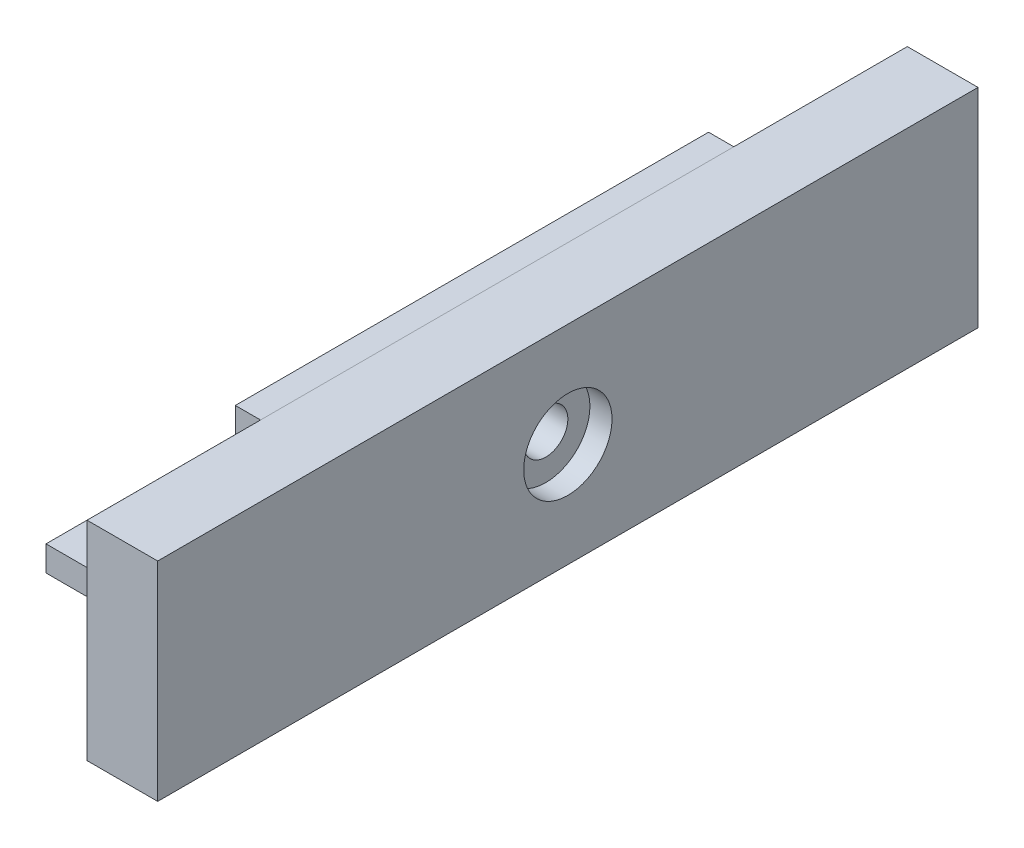
from build123d import *

# Parameters (mm, degrees)
SKETCH1_W           = 130
SKETCH1_H           = 33
SKETCH1_R           = 3.5
BOSS_EXTRUDE1_DEPTH = 11.2
SKETCH2_R           = 7
CUT_EXTRUDE1_DEPTH  = 3.5
BOSS_EXTRUDE2_START = 4
SKETCH3_W           = 75
SKETCH3_H           = 33
SKETCH3_R           = 3.5
BOSS_EXTRUDE2_DEPTH = 4
SKETCH3_3_W         = 75
SKETCH3_3_H         = 38
SKETCH3_3_R         = 3.5
BOSS_EXTRUDE4_DEPTH = 4
SKETCH6_W           = 75
SKETCH6_H           = 4.002033335
BOSS_EXTRUDE6_DEPTH = 30


with BuildPart() as part:
    # Sketch1 → Boss-Extrude1 (new body)
    with BuildSketch(Plane(origin=(0, 0, 0), x_dir=(0, 0, -1), z_dir=(1, 0, 0))):
        Rectangle(SKETCH1_W, SKETCH1_H)
        Circle(SKETCH1_R, mode=Mode.SUBTRACT)
    extrude(amount=BOSS_EXTRUDE1_DEPTH)

    # Sketch2 → Cut-Extrude1 (cut)
    with BuildSketch(Plane(origin=(11.2, 0, 0), x_dir=(0, 0, -1), z_dir=(1, 0, 0))):
        Circle(SKETCH2_R)
    extrude(amount=-CUT_EXTRUDE1_DEPTH, mode=Mode.SUBTRACT)

    # Sketch3 → Boss-Extrude2 (add)
    with BuildSketch(Plane.ZY.offset(BOSS_EXTRUDE2_START)):
        Rectangle(SKETCH3_W, SKETCH3_H)
        Circle(SKETCH3_R, mode=Mode.SUBTRACT)
    extrude(amount=-BOSS_EXTRUDE2_DEPTH)


with BuildPart() as body_2:
    # Sketch3_3 → Boss-Extrude4 (new body)
    with BuildSketch(Plane.ZY):
        with Locations((0, -2.5)):
            Rectangle(SKETCH3_3_W, SKETCH3_3_H)
        Circle(SKETCH3_3_R, mode=Mode.SUBTRACT)
    extrude(amount=BOSS_EXTRUDE4_DEPTH)

    # Sketch6 → Boss-Extrude6 (add)
    with BuildSketch(Plane.ZY.offset(4)):
        with Locations((0, -19.498983332)):
            Rectangle(SKETCH6_W, SKETCH6_H)
    extrude(amount=BOSS_EXTRUDE6_DEPTH)


solid = Compound([part.part, body_2.part])
